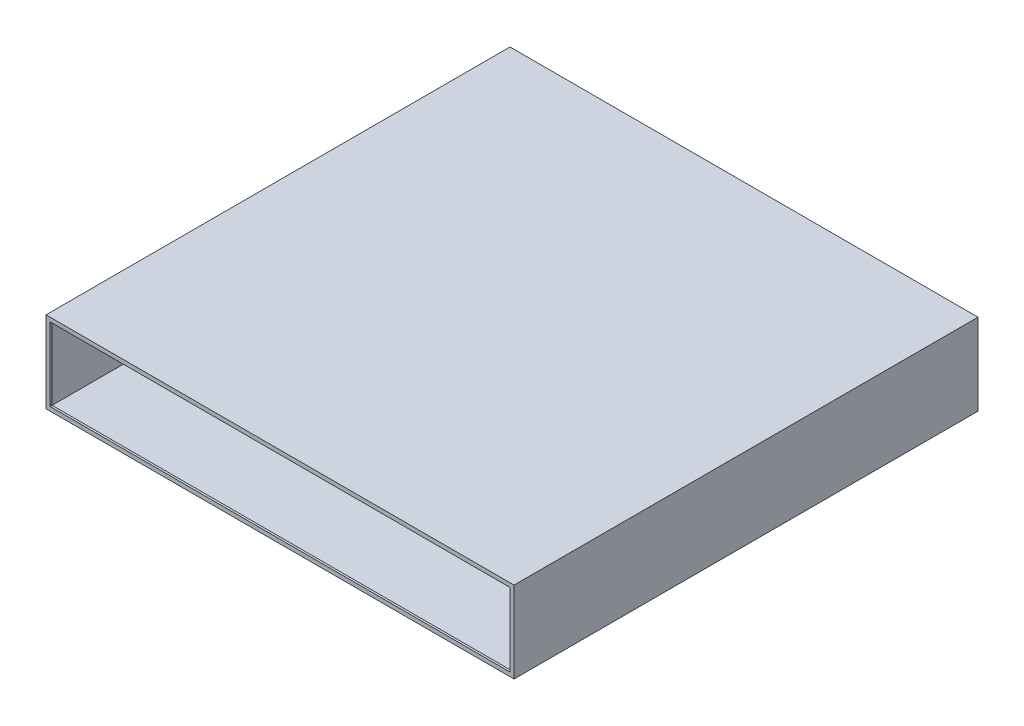
from build123d import *

# Parameters (mm, degrees)
SKETCH_1_W        = 461.2
SKETCH_1_H        = 80.2
SKETCH_1_W_2      = 457.2
SKETCH_1_H_2      = 76.2
EXTRUDE_1_DEPTH   = 457.2
SKETCH_2_W        = 461.2
SKETCH_2_H        = 80.2
SKETCH_2_W_2      = 453.2
SKETCH_2_H_2      = 72.2
EXTRUDE_1_2_DEPTH = 2


with BuildPart() as part:
    # Эскиз1 → Extrude 1 (new body)
    with BuildSketch(Plane.XY):
        Rectangle(SKETCH_1_W, SKETCH_1_H)
        Rectangle(SKETCH_1_W_2, SKETCH_1_H_2, mode=Mode.SUBTRACT)
    extrude(amount=EXTRUDE_1_DEPTH)

    # Эскиз2 → Extrude 1 2 (add)
    with BuildSketch(Plane.XY.offset(457.2)):
        Rectangle(SKETCH_2_W, SKETCH_2_H)
        Rectangle(SKETCH_2_W_2, SKETCH_2_H_2, mode=Mode.SUBTRACT)
    extrude(amount=-EXTRUDE_1_2_DEPTH)


solid = part.part
